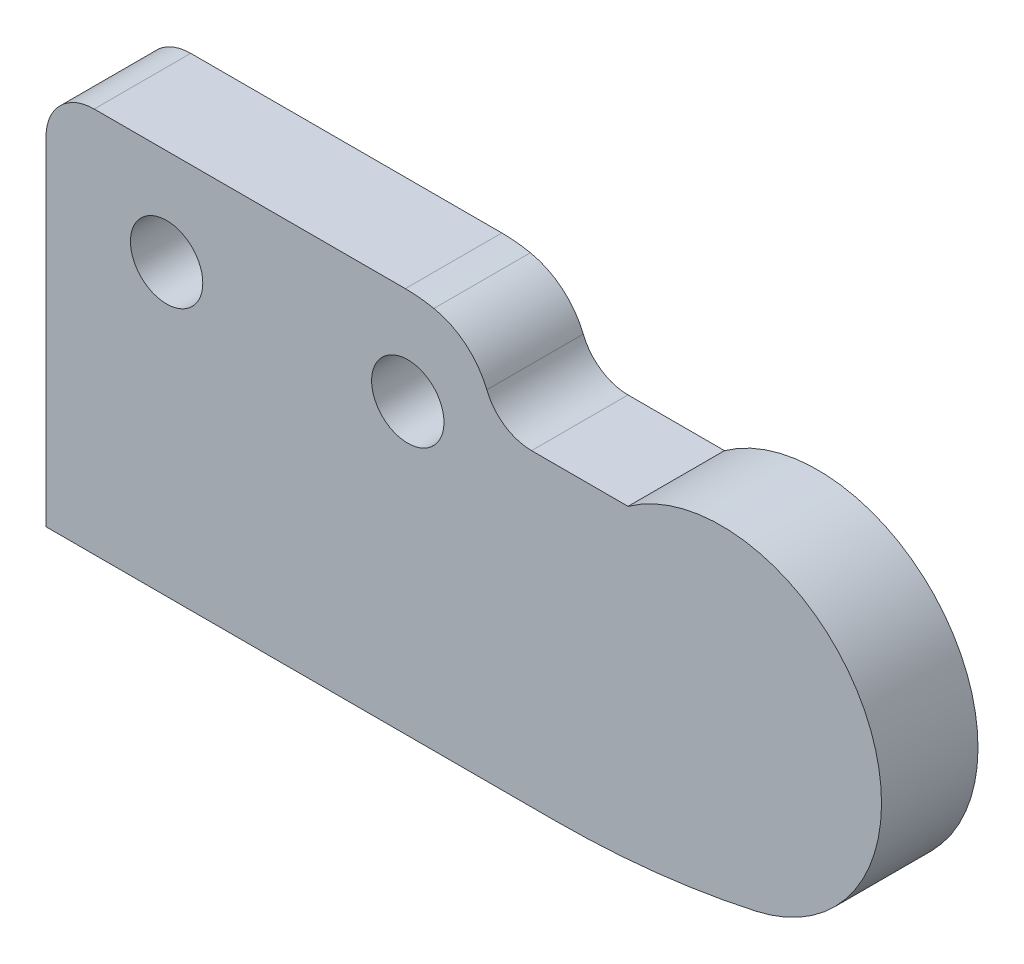
from build123d import *

# Parameters (mm, degrees)
SKETCH1_R           = 0.75
BOSS_EXTRUDE1_DEPTH = 2


with BuildPart() as part:
    # Sketch1 → Boss-Extrude1 (new body)
    with BuildSketch(Plane.XY):
        with BuildLine():
            Line((4.948803726, 2), (-1.5, 2))
            ThreePointArc((-1.5, 2), (-2.207106781, 1.707106781), (-2.5, 1))
            Line((-2.5, 1), (-2.5, -6))
            Line((-2.5, -6), (8.03164583, -6))
            ThreePointArc((8.03164583, -6), (10.136786902, -5.885360204), (12.217030025, -5.542796686))
            ThreePointArc((12.217030025, -5.542796686), (14.533048705, -0.947048427), (9.566127614, 0.4))
            Line((9.566127614, 0.4), (7.566127614, 0.4))
            ThreePointArc((7.566127614, 0.4), (7.005701644, 0.571795477), (6.637832967, 1.028154536))
            ThreePointArc((6.637832967, 1.028154536), (6.20529876, 1.623025524), (5.541978268, 1.940772681))
            ThreePointArc((5.541978268, 1.940772681), (5.246865763, 1.985156448), (4.948803726, 2))
        make_face()
        Circle(SKETCH1_R, mode=Mode.SUBTRACT)
        with Locations((5, 0)):
            Circle(SKETCH1_R, mode=Mode.SUBTRACT)
    extrude(amount=BOSS_EXTRUDE1_DEPTH)


solid = part.part
